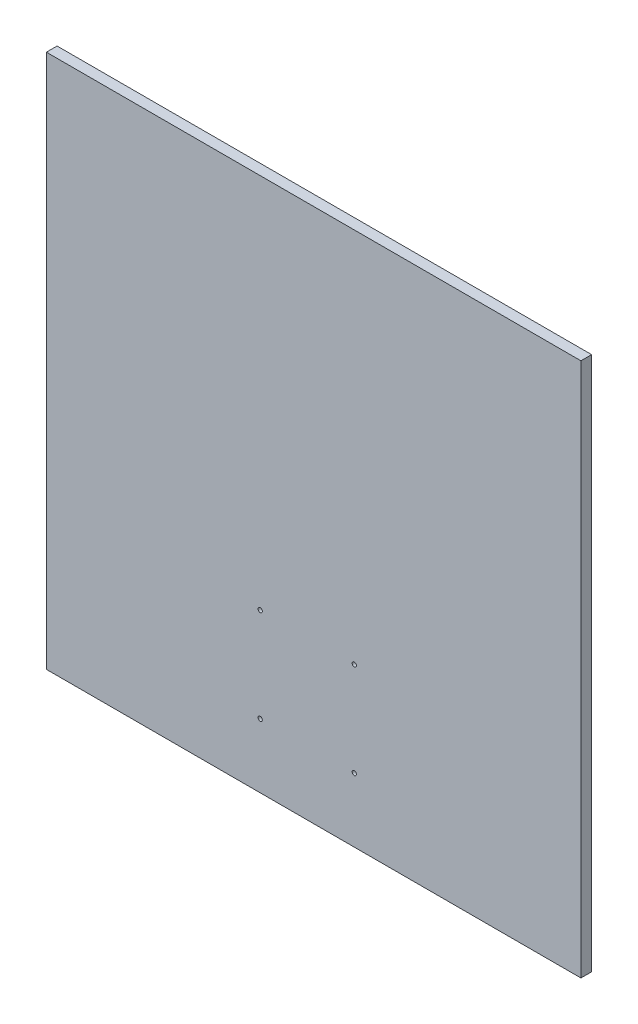
from build123d import *

# Parameters (mm, degrees)
ESQUISSE1_W        = 250
ESQUISSE1_H        = 250
ESQUISSE1_R        = 1
BOSS_EXTRU_1_DEPTH = 5


with BuildPart() as part:
    # Esquisse1 → Boss.-Extru.1 (new body)
    with BuildSketch(Plane.XY):
        with Locations((125, 125)):
            Rectangle(ESQUISSE1_W, ESQUISSE1_H)
        with Locations((100, 30)):
            Circle(ESQUISSE1_R, mode=Mode.SUBTRACT)
        with Locations((144, 30)):
            Circle(ESQUISSE1_R, mode=Mode.SUBTRACT)
        with Locations((144, 74)):
            Circle(ESQUISSE1_R, mode=Mode.SUBTRACT)
        with Locations((100, 74)):
            Circle(ESQUISSE1_R, mode=Mode.SUBTRACT)
    extrude(amount=BOSS_EXTRU_1_DEPTH)


solid = part.part
